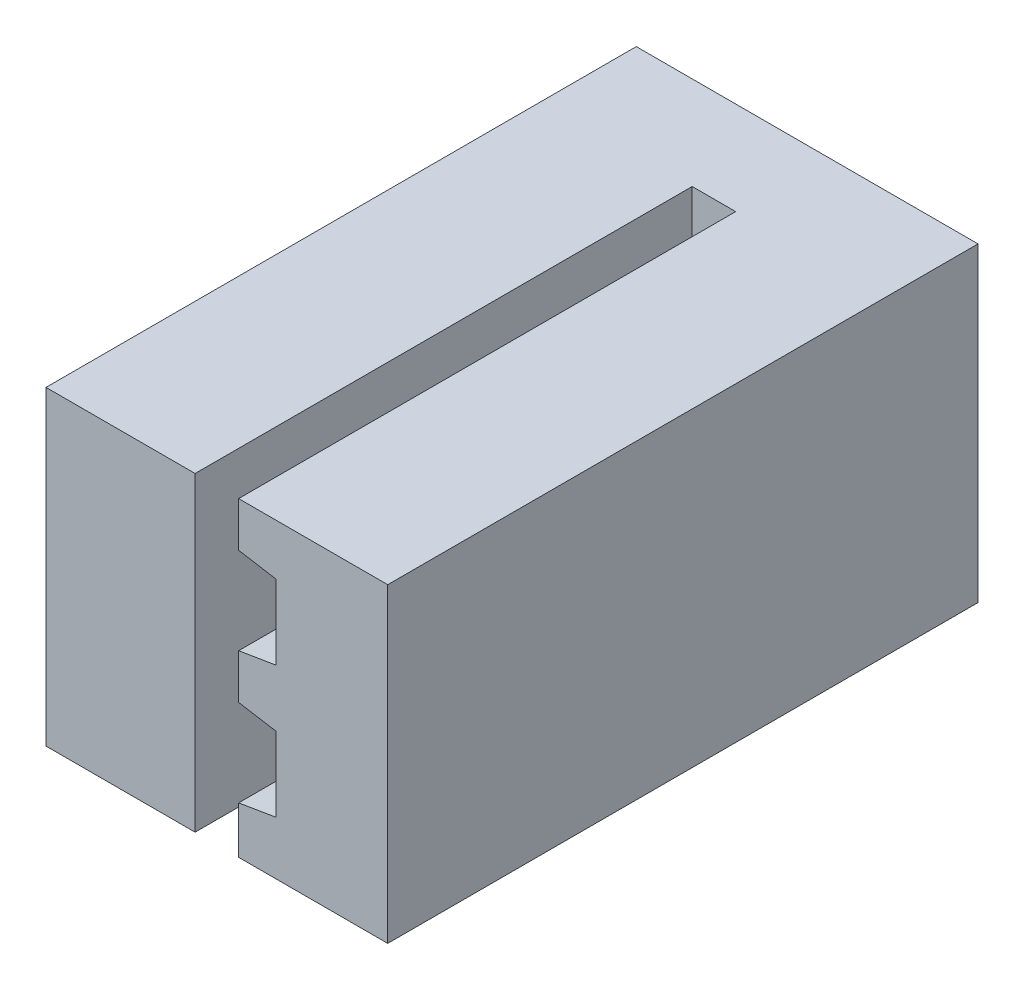
from build123d import *

# Parameters (mm, degrees)
SALIENTE_EXTRUIR1_DEPTH   = 8
CROQUIS1_W                = 2.4
CROQUIS1_H                = 7.15885354
SALIENTE_EXTRUIR1_2_DEPTH = 8
CROQUIS2_W                = 5.5
CROQUIS2_H                = 7.15885354
SALIENTE_EXTRUIR2_DEPTH   = 1.5
CROQUIS3_W                = 5.5
CROQUIS3_H                = 2.15885354
CORTAR_EXTRUIR1_DEPTH     = 10.5


with BuildPart() as part:
    # Croquis1 → Saliente-Extruir1 (new body)
    with BuildSketch(Plane.XY):
        Polygon((0, 7.15885354), (0, 6.4), (0.6, 6.3), (0.6, 5.1), (0, 5), (0, 4.279426768), (0.6, 4.179426768), (0.6, 2.979426768), (0, 2.879426768), (0, 2.158853536), (0.6, 2.058853536), (0.6, 0.858853536), (0, 0.758853536), (0, 0), (2.4, 0), (2.4, 7.15885354), align=None)
    extrude(amount=SALIENTE_EXTRUIR1_DEPTH)



with BuildPart() as body_2:
    # Croquis1 → Saliente-Extruir1 2 (new body)
    with BuildSketch(Plane.XY):
        with Locations((-1.9, 3.57942677)):
            Rectangle(CROQUIS1_W, CROQUIS1_H)
    extrude(amount=SALIENTE_EXTRUIR1_2_DEPTH)


with BuildPart() as part_1:
    add(part.part)

    add(body_2.part)  # Saliente-Extruir2 merges body 2
    # Croquis2 → Saliente-Extruir2 (add)
    with BuildSketch(Plane(origin=(0, 0, 0), x_dir=(-1, 0, 0), z_dir=(0, 0, -1))):
        with Locations((0.35, 3.57942677)):
            Rectangle(CROQUIS2_W, CROQUIS2_H)
    extrude(amount=SALIENTE_EXTRUIR2_DEPTH)

    # Croquis3 → Cortar-Extruir1 (cut, through all)
    with BuildSketch(Plane.XY.offset(8)):
        with Locations((-0.35, 6.07942677)):
            Rectangle(CROQUIS3_W, CROQUIS3_H)
    extrude(amount=-CORTAR_EXTRUIR1_DEPTH, mode=Mode.SUBTRACT)


solid = part_1.part
